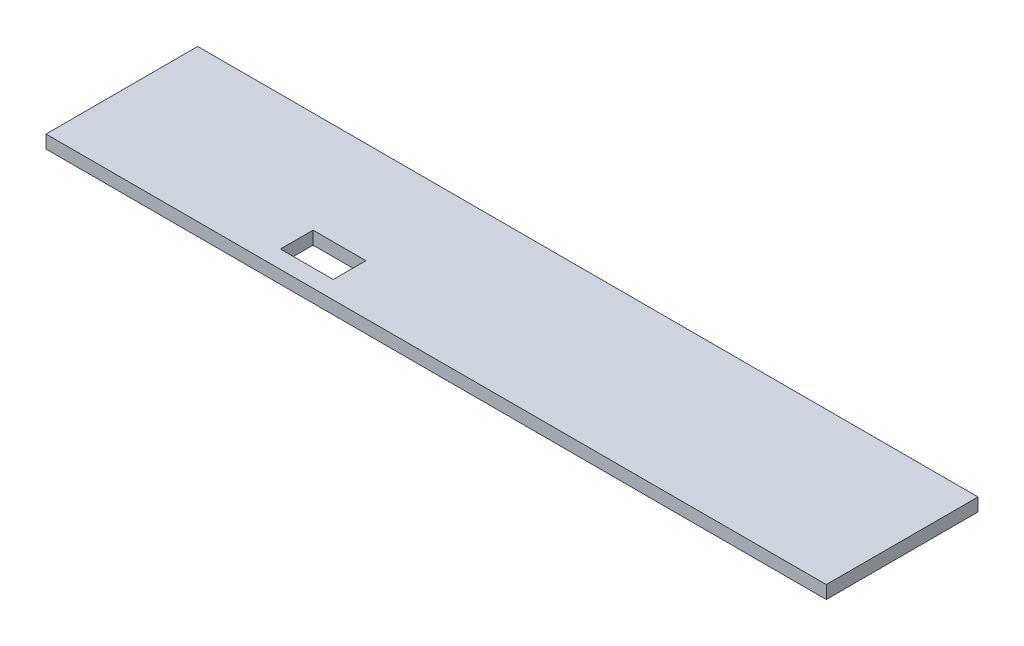
from build123d import *

# Parameters (mm, degrees)
SKETCH1_W           = 180
SKETCH1_H           = 35
BOSS_EXTRUDE1_DEPTH = 3
SKETCH2_W           = 12.2
SKETCH2_H           = 7.53
CUT_EXTRUDE1_DEPTH  = 4


with BuildPart() as part:
    # Sketch1 → Boss-Extrude1 (new body)
    with BuildSketch(Plane(origin=(0, 0, 0), x_dir=(1, 0, 0), z_dir=(0, 1, 0))):
        with Locations((-14.686936777, 41.10573468)):
            Rectangle(SKETCH1_W, SKETCH1_H)
    extrude(amount=BOSS_EXTRUDE1_DEPTH)

    # Sketch2 → Cut-Extrude1 (cut, through all)
    with BuildSketch(Plane(origin=(0, 3, 0), x_dir=(1, 0, 0), z_dir=(0, 1, 0))):
        with Locations((-48.586936777, 31.44073468)):
            Rectangle(SKETCH2_W, SKETCH2_H)
    extrude(amount=-CUT_EXTRUDE1_DEPTH, mode=Mode.SUBTRACT)


solid = part.part
